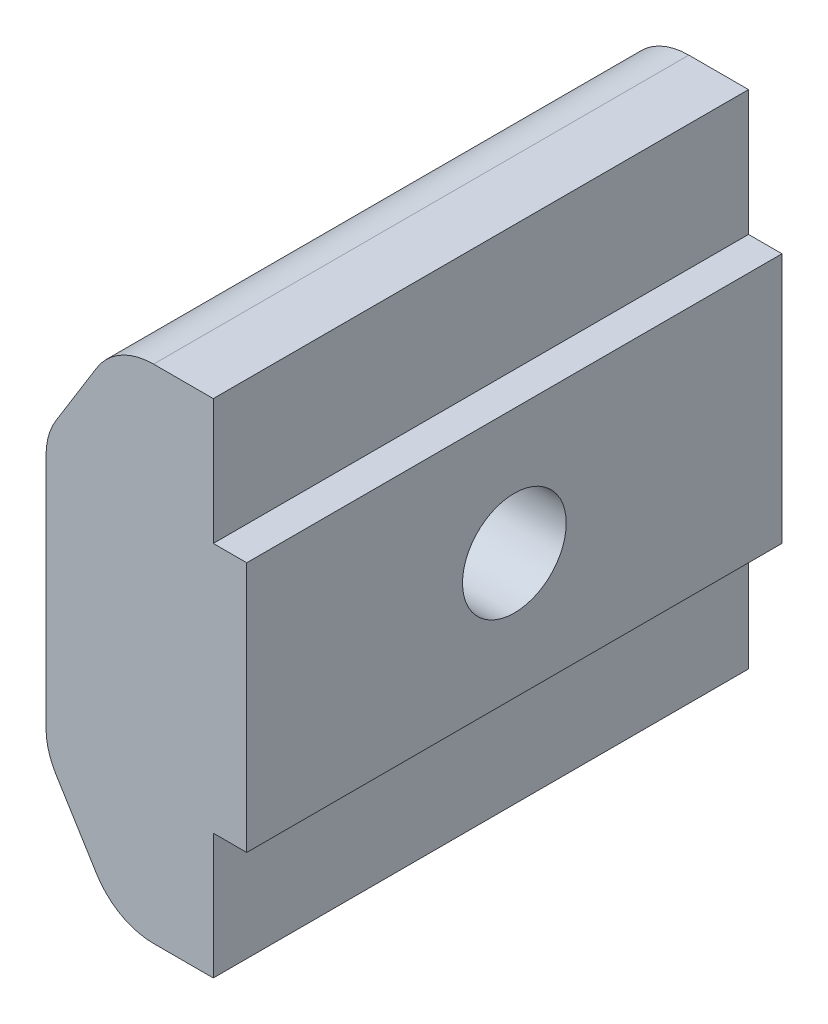
from build123d import *

# Parameters (mm, degrees)
SALIENTE_EXTRUIR1_DEPTH = 16
CROQUIS2_R              = 1.55
CORTAR_EXTRUIR1_DEPTH   = 5
CORTAR_EXTRUIR2_DEPTH   = 2.5
REDONDEO1_R             = 2
CROQUIS4_W              = 16
CROQUIS4_H              = 7.5
CROQUIS4_R              = 1.55
SALIENTE_EXTRUIR3_DEPTH = 1


with BuildPart() as part:
    # Croquis1 → Saliente-Extruir1 (new body)
    with BuildSketch(Plane.XY):
        Polygon((2.1, -3.4), (5, -3.4), (5, 11.6), (2.1, 11.6), (0, 8.2), (0, 0), align=None)
    extrude(amount=SALIENTE_EXTRUIR1_DEPTH)

    # Croquis2 → Cortar-Extruir1 (cut)
    with BuildSketch(Plane.ZY):
        with Locations(Location((8, 4.1, 0), (0, 0, 270))):
            Circle(CROQUIS2_R)
    extrude(amount=-CORTAR_EXTRUIR1_DEPTH, mode=Mode.SUBTRACT)

    # Croquis3 → Cortar-Extruir2 (cut)
    with BuildSketch(Plane.ZY):
        Polygon((11.348631561, 4.1), (9.674315781, 7), (6.325684219, 7), (4.651368439, 4.1), (6.325684219, 1.2), (9.674315781, 1.2), align=None)
    extrude(amount=-CORTAR_EXTRUIR2_DEPTH, mode=Mode.SUBTRACT)

    # Redondeo1
    redondeo1_edges = [part.edges().sort_by_distance(p)[0] for p in [
        (2.1, -3.4, 8),
        (0, 0, 8),
        (0, 8.2, 8),
        (2.1, 11.6, 8),
    ]]
    fillet(redondeo1_edges, radius=REDONDEO1_R)

    # Croquis4 → Saliente-Extruir3 (add)
    with BuildSketch(Plane(origin=(5, 0, 0), x_dir=(0, 0, -1), z_dir=(1, 0, 0))):
        with Locations((-8, 4.1)):
            Rectangle(CROQUIS4_W, CROQUIS4_H)
        with Locations(Location((-8, 4.1, 0), (0, 0, 270))):
            Circle(CROQUIS4_R, mode=Mode.SUBTRACT)
    extrude(amount=SALIENTE_EXTRUIR3_DEPTH)


solid = part.part
